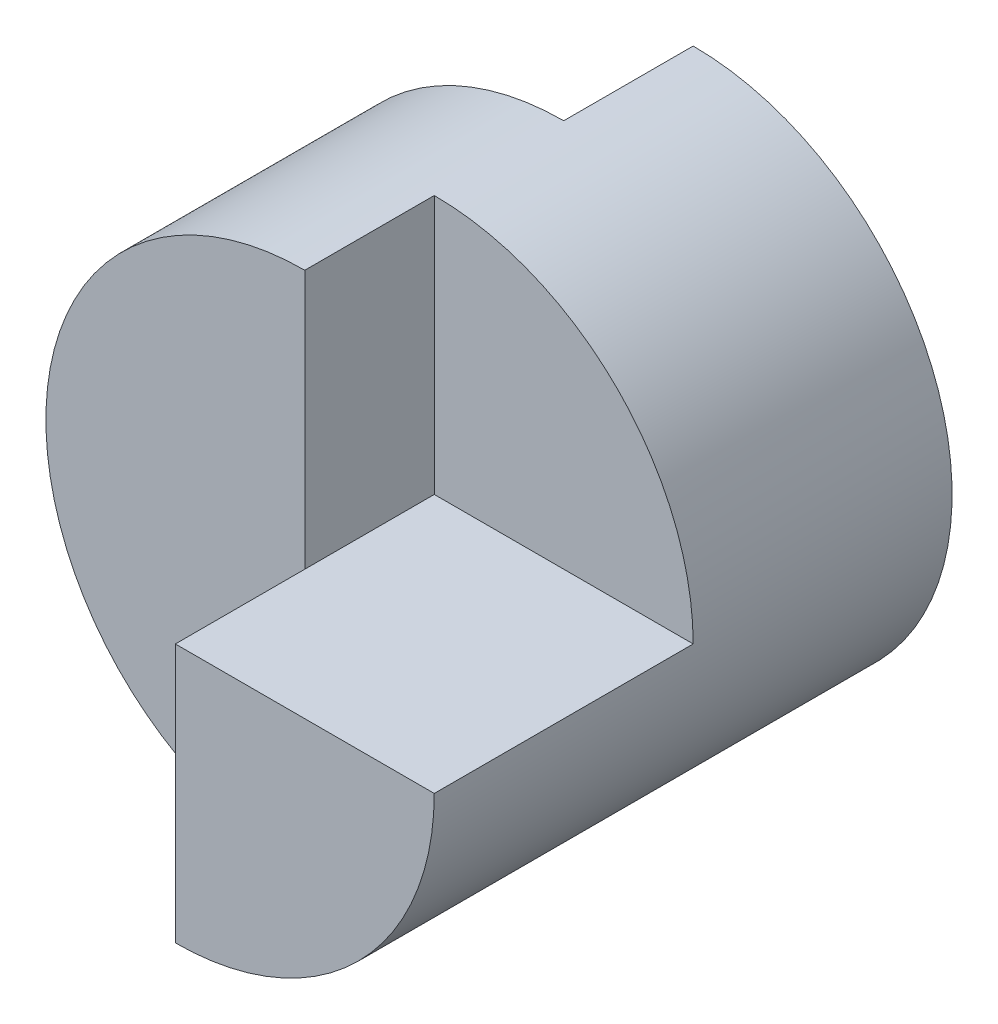
from build123d import *

# Parameters (mm, degrees)
SKETCH1_R               = 20
BOSS_EXTRUDE1_DEPTH     = 40
CUT_EXTRUDE1_DEPTH      = 40
CUT_EXTRUDE1_DEPTH_BACK = 40
SKETCH2_W               = 20
SKETCH2_H               = 10
CUT_EXTRUDE2_START      = -20
CUT_EXTRUDE2_DEPTH      = 20


with BuildPart() as part:
    # Sketch1 → Boss-Extrude1 (new body)
    with BuildSketch(Plane.XY):
        Circle(SKETCH1_R)
    extrude(amount=BOSS_EXTRUDE1_DEPTH)

    # Sketch2 → Cut-Extrude1 (cut, two sides: drawn at the far end of the back side and taken through both)
    with BuildSketch(Plane(origin=(0, 0, 0), x_dir=(1, 0, 0), z_dir=(0, 1, 0)).offset(-CUT_EXTRUDE1_DEPTH_BACK)):
        with Locations((-10, -5)):
            Rectangle(SKETCH2_W, SKETCH2_H)
        with Locations((-10, -35)):
            Rectangle(SKETCH2_W, SKETCH2_H)
    extrude(amount=CUT_EXTRUDE1_DEPTH + CUT_EXTRUDE1_DEPTH_BACK, mode=Mode.SUBTRACT)

    # Sketch3 → Cut-Extrude2 (cut)
    with BuildSketch(Plane.XY.offset(40).offset(CUT_EXTRUDE2_START)):
        with BuildLine():
            Line((0, 0), (20, 0))
            ThreePointArc((20, 0), (14.142135624, 14.142135624), (0, 20))
            Line((0, 20), (0, 0))
        make_face()
    extrude(amount=CUT_EXTRUDE2_DEPTH, mode=Mode.SUBTRACT)


solid = part.part
